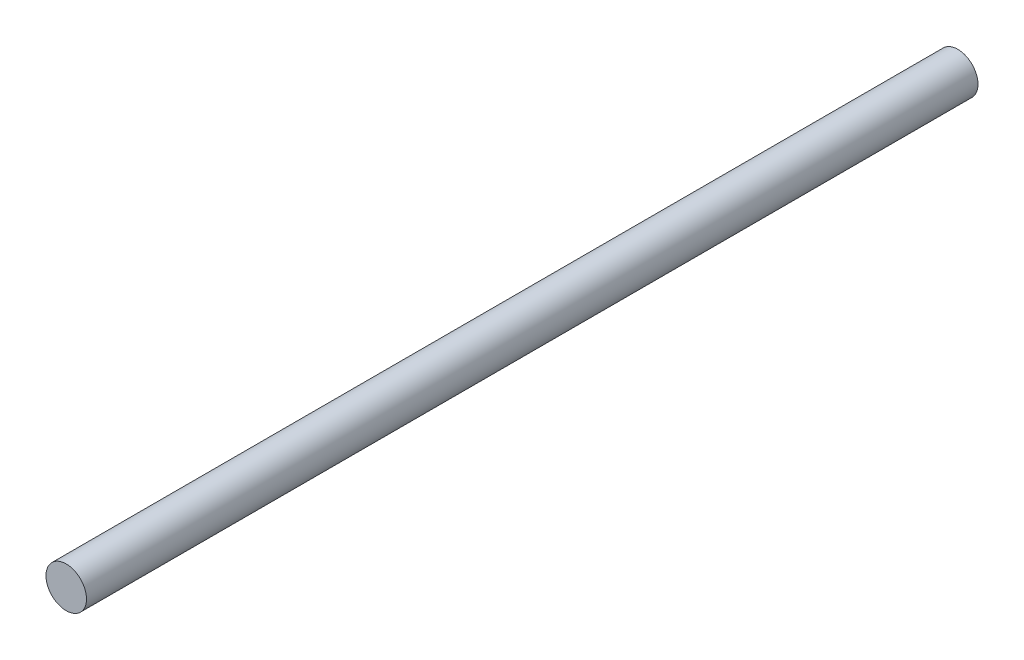
from build123d import *

# Parameters (mm, degrees)
ESBO_O1_R                = 4
RESSALTO_EXTRUS_O1_DEPTH = 176


with BuildPart() as part:
    # Esboço1 → Ressalto-extrusão1 (new body)
    with BuildSketch(Plane.XY):
        Circle(ESBO_O1_R)
    extrude(amount=RESSALTO_EXTRUS_O1_DEPTH)


solid = part.part
